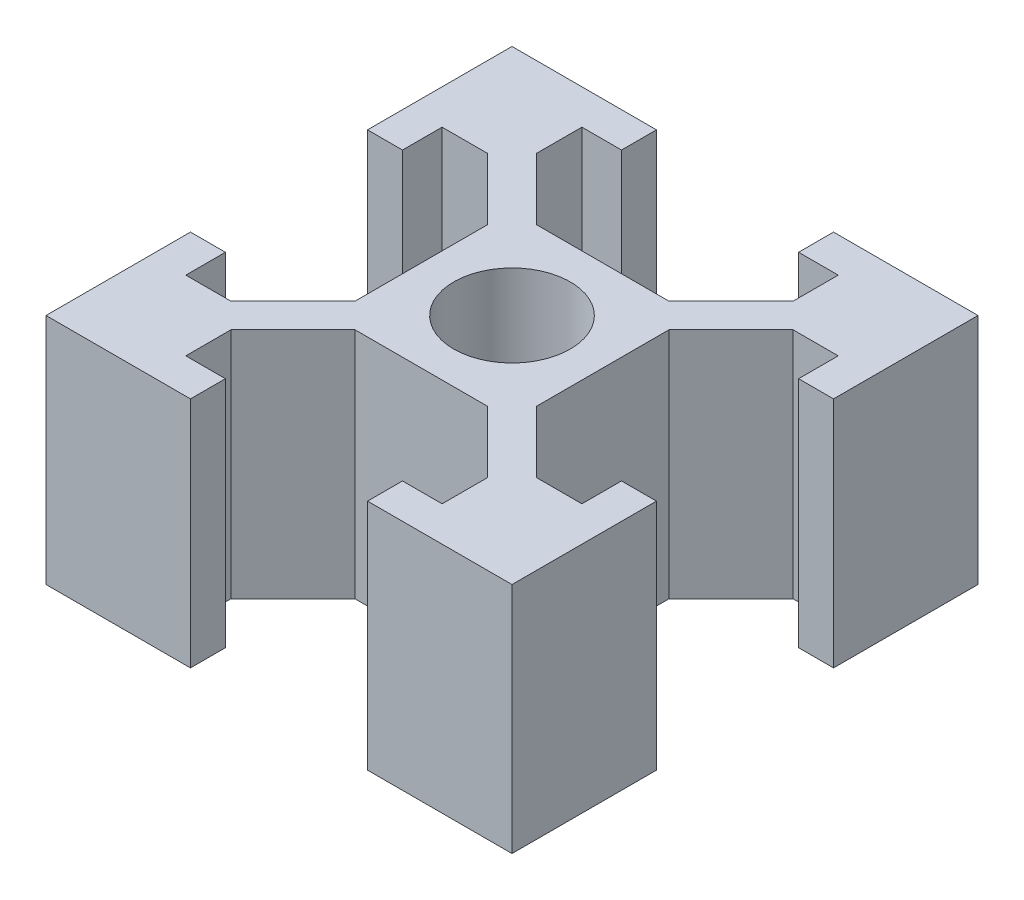
from build123d import *

# Parameters (mm, degrees)
SKETCH_1_W      = 1.5
SKETCH_1_H      = 1.7
SKETCH_1_W_2    = 1.7
SKETCH_1_H_2    = 1.5
SKETCH_1_W_3    = 7.8
SKETCH_1_H_3    = 7.8
SKETCH_1_R      = 2.5
EXTRUDE_1_DEPTH = 10


with BuildPart() as part:
    # 草图1 → 凸台-拉伸1 (new body)
    with BuildSketch(Plane(origin=(0, 0, 0), x_dir=(1, 0, 0), z_dir=(0, 1, 0))):
        Polygon((5.5, 8.5), (5.5, 6.560660172), (5.5, 5.5), (6.560660172, 5.5), (8.5, 5.5), (10, 5.5), (10, 10), (5.5, 10), align=None)
        with Locations((9.25, 4.65)):
            Rectangle(SKETCH_1_W, SKETCH_1_H)
        Polygon((5.5, 6.560660172), (2.839339828, 3.9), (3.9, 3.9), (3.9, 2.839339828), (6.560660172, 5.5), (5.5, 5.5), align=None)
        with Locations((4.65, 9.25)):
            Rectangle(SKETCH_1_W_2, SKETCH_1_H_2)
        Rectangle(SKETCH_1_W_3, SKETCH_1_H_3)
        Circle(SKETCH_1_R, mode=Mode.SUBTRACT)
        with Locations((-4.65, 9.25)):
            Rectangle(SKETCH_1_W_2, SKETCH_1_H_2)
        Polygon((-8.5, 5.5), (-6.560660172, 5.5), (-5.5, 5.5), (-5.5, 6.560660172), (-5.5, 8.5), (-5.5, 10), (-10, 10), (-10, 5.5), align=None)
        with Locations((-9.25, 4.65)):
            Rectangle(SKETCH_1_W, SKETCH_1_H)
        Polygon((-5.5, 5.5), (-6.560660172, 5.5), (-3.9, 2.839339828), (-3.9, 3.9), (-2.839339828, 3.9), (-5.5, 6.560660172), align=None)
        Polygon((-5.5, -5.5), (-6.560660172, -5.5), (-8.5, -5.5), (-10, -5.5), (-10, -10), (-5.5, -10), (-5.5, -8.5), (-5.5, -6.560660172), align=None)
        with Locations((-4.65, -9.25)):
            Rectangle(SKETCH_1_W_2, SKETCH_1_H_2)
        with Locations((-9.25, -4.65)):
            Rectangle(SKETCH_1_W, SKETCH_1_H)
        Polygon((-3.9, -3.9), (-3.9, -2.839339828), (-6.560660172, -5.5), (-5.5, -5.5), (-5.5, -6.560660172), (-2.839339828, -3.9), align=None)
        Polygon((3.9, -3.9), (2.839339828, -3.9), (5.5, -6.560660172), (5.5, -5.5), (6.560660172, -5.5), (3.9, -2.839339828), align=None)
        Polygon((5.5, -5.5), (5.5, -6.560660172), (5.5, -8.5), (5.5, -10), (10, -10), (10, -5.5), (8.5, -5.5), (6.560660172, -5.5), align=None)
        with Locations((9.25, -4.65)):
            Rectangle(SKETCH_1_W, SKETCH_1_H)
        with Locations((4.65, -9.25)):
            Rectangle(SKETCH_1_W_2, SKETCH_1_H_2)
    extrude(amount=EXTRUDE_1_DEPTH)


solid = part.part
